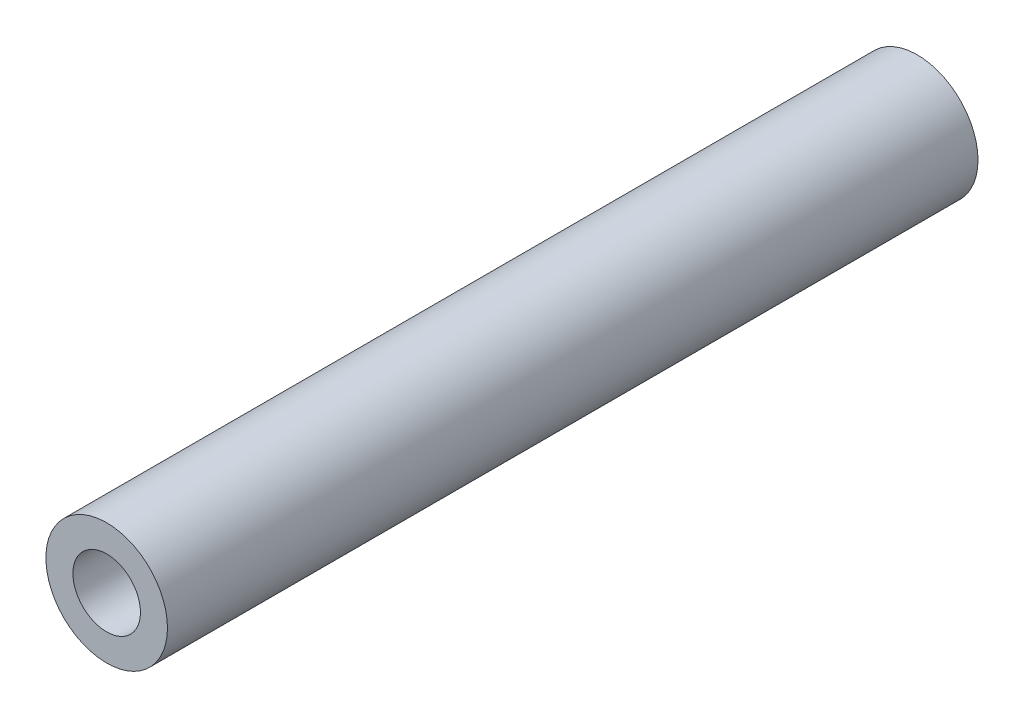
from build123d import *

# Parameters (mm, degrees)
SKETCH1_R           = 2.8575
SKETCH1_R_2         = 1.5875
BOSS_EXTRUDE1_DEPTH = 38.1


with BuildPart() as part:
    # Sketch1 → Boss-Extrude1 (new body)
    with BuildSketch(Plane.XY):
        Circle(SKETCH1_R)
        Circle(SKETCH1_R_2, mode=Mode.SUBTRACT)
    extrude(amount=BOSS_EXTRUDE1_DEPTH)


solid = part.part
